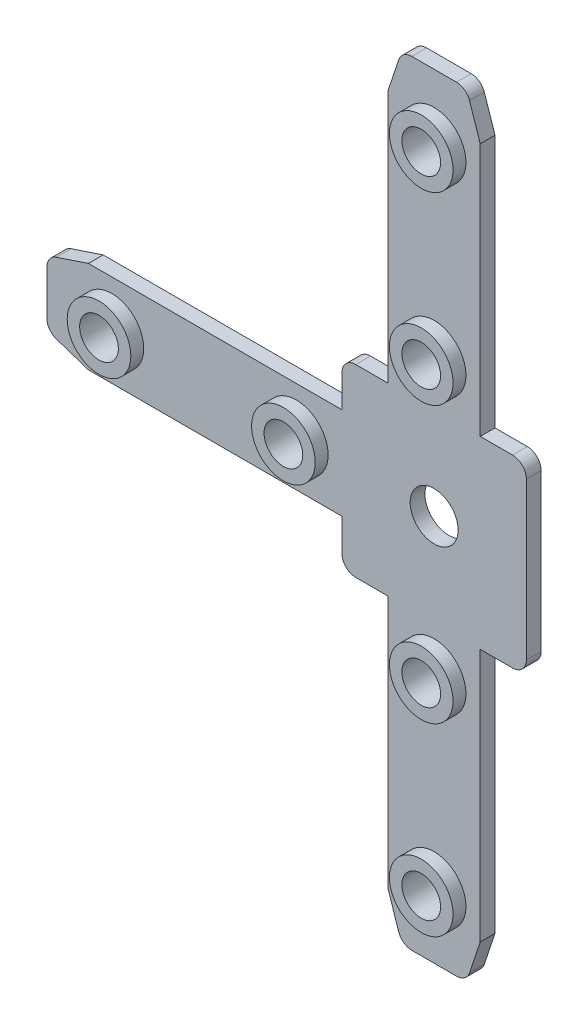
from build123d import *

# Parameters (mm, degrees)
SKETCH1_R             = 2.6
BOSS_EXTRUDE1_DEPTH   = 1.6
SKETCH2_R             = 3.45
BOSS_EXTRUDE2_DEPTH   = 1.4
M5X0_8_TAPPED_HOLE1_D = 4.2


with BuildPart() as part:
    # Sketch1 → Boss-Extrude1 (new body)
    with BuildSketch(Plane.XY):
        with BuildLine():
            Line((-10, -8.5), (-10, -5))
            Line((-10, -5), (-37.5, -5))
            Line((-37.5, -5), (-40.974341649, -3.841886117))
            ThreePointArc((-40.974341649, -3.841886117), (-41.716863278, -3.295926597), (-42, -2.41886117))
            Line((-42, -2.41886117), (-42, 2.41886117))
            ThreePointArc((-42, 2.41886117), (-41.716863278, 3.295926597), (-40.974341649, 3.841886117))
            Line((-40.974341649, 3.841886117), (-37.5, 5))
            Line((-37.5, 5), (-10, 5))
            Line((-10, 5), (-10, 8.5))
            ThreePointArc((-10, 8.5), (-9.560660172, 9.560660172), (-8.5, 10))
            Line((-8.5, 10), (-5, 10))
            Line((-5, 10), (-5, 37.485))
            Line((-5, 37.485), (-3.841886117, 40.959341649))
            ThreePointArc((-3.841886117, 40.959341649), (-3.295926597, 41.701863278), (-2.41886117, 41.985))
            Line((-2.41886117, 41.985), (2.41886117, 41.985))
            ThreePointArc((2.41886117, 41.985), (3.295926597, 41.701863278), (3.841886117, 40.959341649))
            Line((3.841886117, 40.959341649), (5, 37.485))
            Line((5, 37.485), (5, 10))
            Line((5, 10), (8.5, 10))
            ThreePointArc((8.5, 10), (9.560660172, 9.560660172), (10, 8.5))
            Line((10, 8.5), (10, -8.5))
            ThreePointArc((10, -8.5), (9.560660172, -9.560660172), (8.5, -10))
            Line((8.5, -10), (5, -10))
            Line((5, -10), (5, -37.485))
            Line((5, -37.485), (3.841886117, -40.959341649))
            ThreePointArc((3.841886117, -40.959341649), (3.295926597, -41.701863278), (2.41886117, -41.985))
            Line((2.41886117, -41.985), (-2.41886117, -41.985))
            ThreePointArc((-2.41886117, -41.985), (-3.295926597, -41.701863278), (-3.841886117, -40.959341649))
            Line((-3.841886117, -40.959341649), (-5, -37.485))
            Line((-5, -37.485), (-5, -10))
            Line((-5, -10), (-8.5, -10))
            ThreePointArc((-8.5, -10), (-9.560660172, -9.560660172), (-10, -8.5))
        make_face()
        Circle(SKETCH1_R, mode=Mode.SUBTRACT)
    extrude(amount=BOSS_EXTRUDE1_DEPTH)

    # Sketch2 → Boss-Extrude2 (add)
    with BuildSketch(Plane.XY.offset(1.6)):
        with Locations((0, 14.95)):
            Circle(SKETCH2_R)
        with Locations((0, 34.95)):
            Circle(SKETCH2_R)
        with Locations((0, -14.95)):
            Circle(SKETCH2_R)
        with Locations((0, -34.95)):
            Circle(SKETCH2_R)
        with Locations((-14.95, 0)):
            Circle(SKETCH2_R)
        with Locations((-34.95, 0)):
            Circle(SKETCH2_R)
    extrude(amount=BOSS_EXTRUDE2_DEPTH)

    # M5x0.8 Tapped Hole1 (through all)
    with Locations(Plane.XY.offset(3)):
        with Locations((0, 34.95), (0, 14.95), (0, -14.95), (0, -34.95), (-14.95, 0), (-34.95, 0)):
            Hole(M5X0_8_TAPPED_HOLE1_D / 2)


solid = part.part
